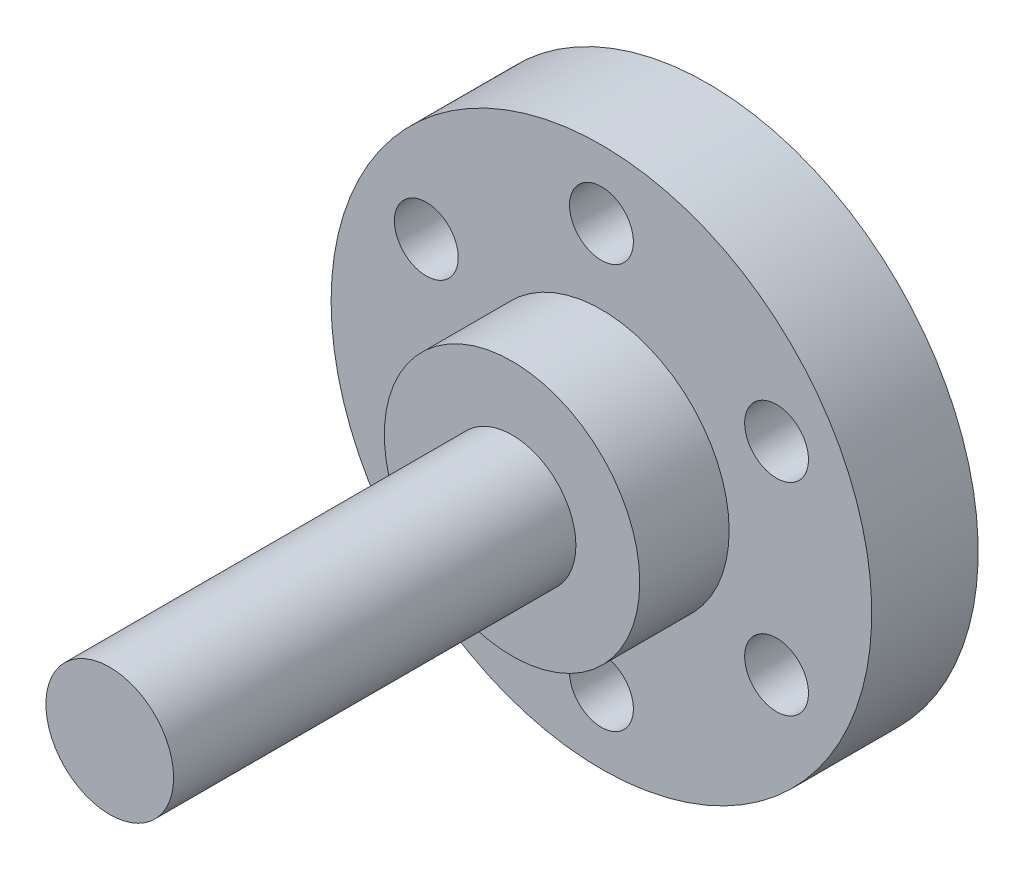
from build123d import *

# Parameters (mm, degrees)
SKETCH1_R           = 3
BOSS_EXTRUDE1_DEPTH = 29
SKETCH2_R           = 6
BOSS_EXTRUDE2_DEPTH = 2.1
SKETCH3_R           = 12.7
BOSS_EXTRUDE3_DEPTH = 5
SKETCH4_R           = 6
BOSS_EXTRUDE4_DEPTH = 2.1
SKETCH10_R          = 1.5
CUT_EXTRUDE1_DEPTH  = 10


with BuildPart() as part:
    # Sketch1 → Boss-Extrude1 (new body)
    with BuildSketch(Plane.XY):
        Circle(SKETCH1_R)
    extrude(amount=BOSS_EXTRUDE1_DEPTH)

    # Sketch2 → Boss-Extrude2 (add)
    with BuildSketch(Plane.XY.offset(8)):
        Circle(SKETCH2_R)
    extrude(amount=-BOSS_EXTRUDE2_DEPTH)

    # Sketch3 → Boss-Extrude3 (add)
    with BuildSketch(Plane(origin=(0, 0, 5.9), x_dir=(-1, 0, 0), z_dir=(0, 0, -1))):
        Circle(SKETCH3_R)
    extrude(amount=BOSS_EXTRUDE3_DEPTH)

    # Sketch4 → Boss-Extrude4 (add)
    with BuildSketch(Plane.XY.offset(8)):
        Circle(SKETCH4_R)
    extrude(amount=BOSS_EXTRUDE4_DEPTH)

    # Sketch10 → Cut-Extrude1 (cut)
    with BuildSketch(Plane(origin=(0, 0, 0.9), x_dir=(-1, 0, 0), z_dir=(0, 0, -1))):
        with Locations((8.227241336, 4.75)):
            Circle(SKETCH10_R)
        with Locations((0, 9.5)):
            Circle(SKETCH10_R)
        with Locations((8.227241336, -4.75)):
            Circle(SKETCH10_R)
        with Locations((0, -9.5)):
            Circle(SKETCH10_R)
        with Locations((-8.227241336, -4.75)):
            Circle(SKETCH10_R)
        with Locations((-8.227241336, 4.75)):
            Circle(SKETCH10_R)
    extrude(amount=-CUT_EXTRUDE1_DEPTH, mode=Mode.SUBTRACT)


solid = part.part
